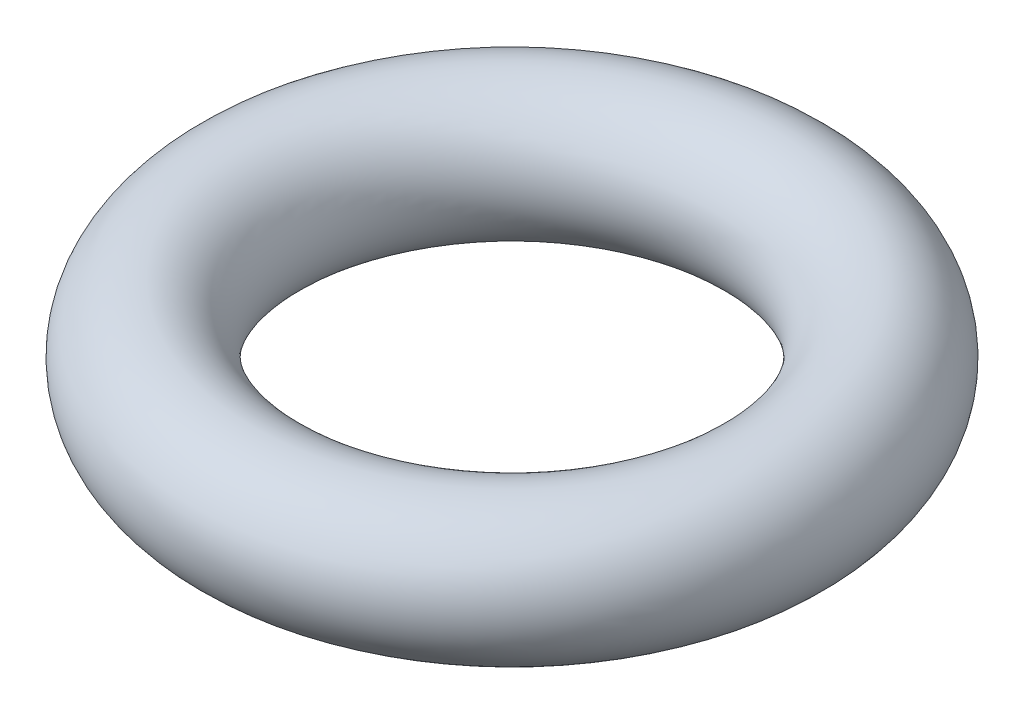
from build123d import *

# Parameters (mm, degrees)
SKETCH1_R = 1.25


with BuildPart() as part:
    # Sketch1 → Revolve1 (revolve)
    with BuildSketch(Plane.XY):
        with Locations((4.75, 0)):
            Circle(SKETCH1_R)
    revolve(axis=Axis((0, 1.25, 0), (0, -1, 0)))


solid = part.part
